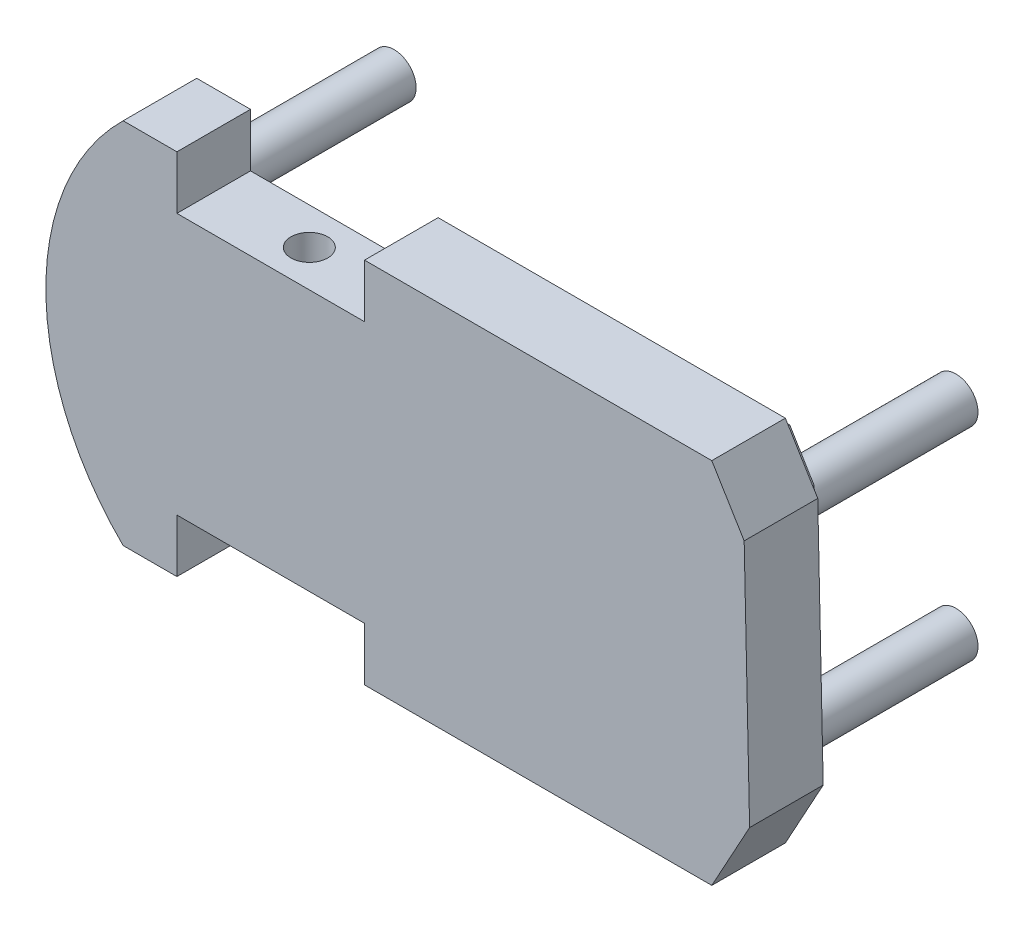
from build123d import *

# Parameters (mm, degrees)
SKETCH5_W               = 160
SKETCH5_H               = 100
BOSS_EXTRUDE2_DEPTH     = 20
SKETCH6_W               = 51
SKETCH6_H               = 15
CUT_EXTRUDE1_DEPTH      = 1
CUT_EXTRUDE1_DEPTH_BACK = 21
SKETCH7_R               = 6
BOSS_EXTRUDE3_DEPTH     = 50
SKETCH8_R               = 5
CUT_EXTRUDE2_DEPTH      = 15.5
CUT_EXTRUDE2_DEPTH_BACK = 86.5
BOSS_EXTRUDE4_DEPTH     = 4
BOSS_EXTRUDE5_DEPTH     = 5


with BuildPart() as part:
    # Sketch5 → Boss-Extrude2 (new body)
    with BuildSketch(Plane.XY):
        with Locations((-1155.707372839, 36.928751241)):
            Rectangle(SKETCH5_W, SKETCH5_H)
        Polygon((-1065.42313354, 5.690501508), (-1075.707372839, -13.071248759), (-1075.707372839, 86.928751241), (-1066.90354904, 72.432300318), align=None)
        with BuildLine():
            Line((-1235.707372839, 86.928751241), (-1235.707372839, -13.071248759))
            ThreePointArc((-1235.707372839, -13.071248759), (-1256.717577983, 36.928751241), (-1235.707372839, 86.928751241))
        make_face()
    extrude(amount=BOSS_EXTRUDE2_DEPTH)

    # Sketch6 → Cut-Extrude1 (cut, two sides)
    with BuildSketch(Plane.XY.offset(20)) as cut_extrude1_sk:
        with Locations((-1195.595351444, -6.071248759)):
            Rectangle(SKETCH6_W, SKETCH6_H)
        with Locations((-1195.595351444, 79.928751241)):
            Rectangle(SKETCH6_W, SKETCH6_H)
    extrude(amount=CUT_EXTRUDE1_DEPTH, mode=Mode.SUBTRACT)
    extrude(cut_extrude1_sk.sketch, amount=-CUT_EXTRUDE1_DEPTH_BACK, mode=Mode.SUBTRACT)

    # Sketch7 → Boss-Extrude3 (add)
    with BuildSketch(Plane(origin=(0, 0, 0), x_dir=(-1, 0, 0), z_dir=(0, 0, -1))):
        with Locations((1079.344915198, 64.512007402)):
            Circle(SKETCH7_R)
        with Locations((1079.344915198, 9.345495081)):
            Circle(SKETCH7_R)
        with Locations((1232.069830479, 9.345495081)):
            Circle(SKETCH7_R)
        with Locations((1232.069830479, 64.512007402)):
            Circle(SKETCH7_R)
    extrude(amount=BOSS_EXTRUDE3_DEPTH)

    # Sketch8 → Cut-Extrude2 (cut, two sides)
    with BuildSketch(Plane.XZ.offset(-1.428751241)) as cut_extrude2_sk:
        with Locations((-1195.095351444, 10)):
            Circle(SKETCH8_R)
    extrude(amount=CUT_EXTRUDE2_DEPTH, mode=Mode.SUBTRACT)
    extrude(cut_extrude2_sk.sketch, amount=-CUT_EXTRUDE2_DEPTH_BACK, mode=Mode.SUBTRACT)

    # Sketch9 → Boss-Extrude4 (add)
    with BuildSketch(Plane(origin=(0, 0, 0), x_dir=(-1, 0, 0), z_dir=(0, 0, -1))):
        with BuildLine():
            Line((1165.095351444, 6.428751241), (1226.095351444, 6.428751241))
            Line((1226.095351444, 6.428751241), (1226.095351444, -8.071248759))
            Line((1226.095351444, -8.071248759), (1233.621735581, -8.071248759))
            ThreePointArc((1233.621735581, -8.071248759), (1251.717577983, 36.928751241), (1233.621735581, 81.928751241))
            Line((1233.621735581, 81.928751241), (1226.095351444, 81.928751241))
            Line((1226.095351444, 81.928751241), (1226.095351444, 67.428751241))
            Line((1226.095351444, 67.428751241), (1165.095351444, 67.428751241))
            Line((1165.095351444, 67.428751241), (1165.095351444, 81.928751241))
            Line((1165.095351444, 81.928751241), (1078.520666135, 81.928751241))
            Line((1078.520666135, 81.928751241), (1071.872609564, 70.982004916))
            Line((1071.872609564, 70.982004916), (1070.451613888, 6.919039109))
            Line((1070.451613888, 6.919039109), (1078.668528909, -8.071248759))
            Line((1078.668528909, -8.071248759), (1165.095351444, -8.071248759))
            Line((1165.095351444, -8.071248759), (1165.095351444, 6.428751241))
        make_face()
    extrude(amount=BOSS_EXTRUDE4_DEPTH)

    # Sketch10 → Boss-Extrude5 (add)
    with BuildSketch(Plane(origin=(0, 0, 0), x_dir=(-1, 0, 0), z_dir=(0, 0, -1))):
        with BuildLine():
            Line((1170.095351444, 1.428751241), (1221.095351444, 1.428751241))
            Line((1221.095351444, 1.428751241), (1221.095351444, -13.071248759))
            Line((1221.095351444, -13.071248759), (1235.707372839, -13.071248759))
            ThreePointArc((1235.707372839, -13.071248759), (1256.717577983, 36.928751241), (1235.707372839, 86.928751241))
            Line((1235.707372839, 86.928751241), (1221.095351444, 86.928751241))
            Line((1221.095351444, 86.928751241), (1221.095351444, 72.428751241))
            Line((1221.095351444, 72.428751241), (1170.095351444, 72.428751241))
            Line((1170.095351444, 72.428751241), (1170.095351444, 86.928751241))
            Line((1170.095351444, 86.928751241), (1075.707372839, 86.928751241))
            Line((1075.707372839, 86.928751241), (1066.90354904, 72.432300318))
            Line((1066.90354904, 72.432300318), (1065.42313354, 5.690501508))
            Line((1065.42313354, 5.690501508), (1075.707372839, -13.071248759))
            Line((1075.707372839, -13.071248759), (1170.095351444, -13.071248759))
            Line((1170.095351444, -13.071248759), (1170.095351444, 1.428751241))
        make_face()
    extrude(amount=-BOSS_EXTRUDE5_DEPTH)


solid = part.part
